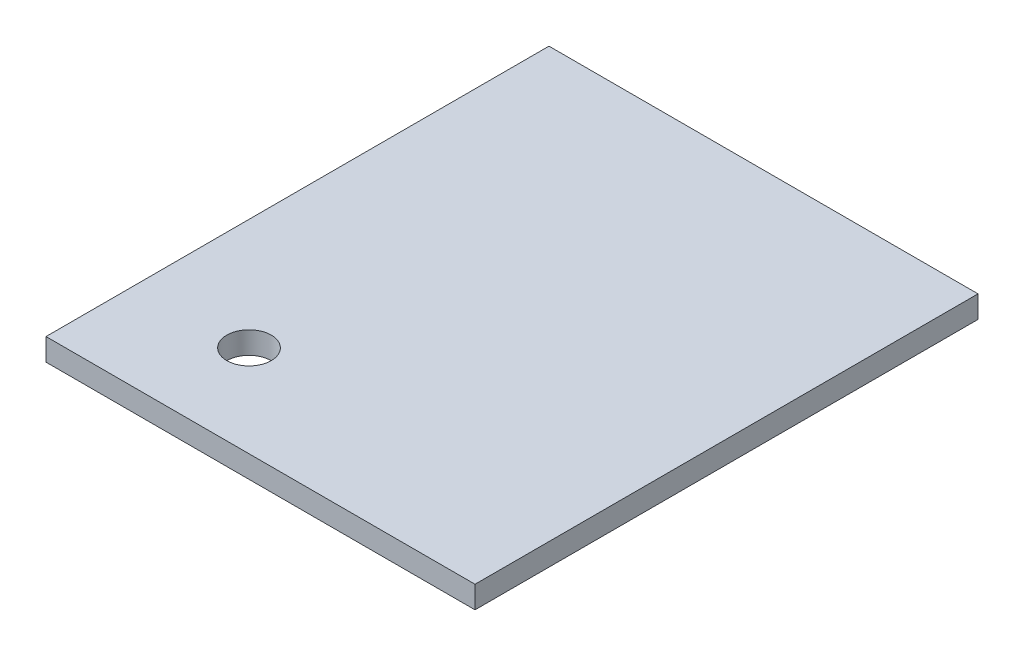
from build123d import *

# Parameters (mm, degrees)
SKETCH1_W                 = 58
SKETCH1_H                 = 68
BOSS_EXTRUDE1_DEPTH       = 3
F_8_0MM_DOWEL_HOLE1_D     = 6
F_8_0MM_DOWEL_HOLE1_DEPTH = 3


with BuildPart() as part:
    # Sketch1 → Boss-Extrude1 (new body)
    with BuildSketch(Plane(origin=(0, 0, 0), x_dir=(1, 0, 0), z_dir=(0, 1, 0))):
        with Locations((2.631421053, -22.558871845)):
            Rectangle(SKETCH1_W, SKETCH1_H)
    extrude(amount=BOSS_EXTRUDE1_DEPTH)

    # Ø8.0mm Dowel Hole1
    with Locations(Plane(origin=(0, 0, 0), x_dir=(-1, 0, 0), z_dir=(0, -1, 0))):
        with Locations((11.319743636, -44.159996598)):
            Hole(F_8_0MM_DOWEL_HOLE1_D / 2, depth=F_8_0MM_DOWEL_HOLE1_DEPTH)


solid = part.part
